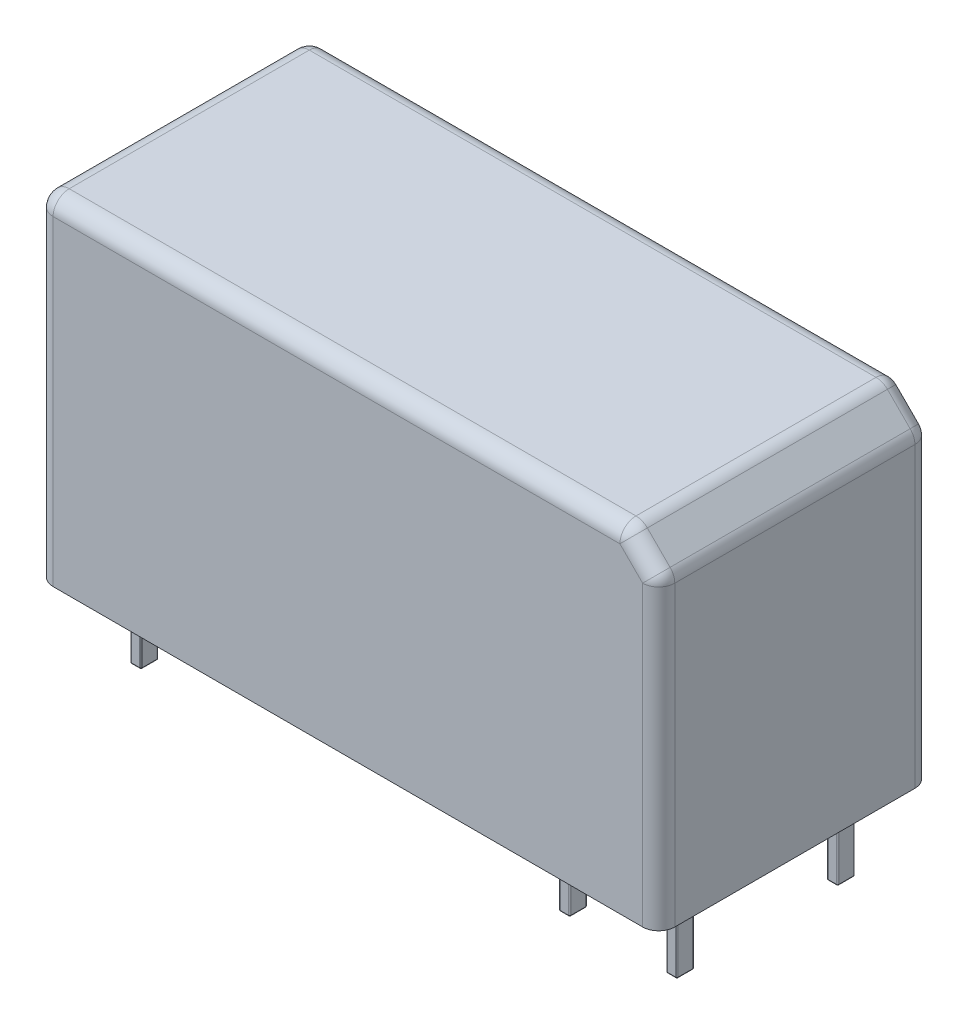
from build123d import *

# Parameters (mm, degrees)
SKETCH_1_W      = 29
SKETCH_1_H      = 12.7
EXTRUDE_1_DEPTH = 15.7
EXTRUDE_2_DEPTH = 3.5
FILLET_1_R      = 0.05
CHAMFER_1_SIZE  = 1.5
FILLET_2_R      = 0.75


with BuildPart() as part:
    # Эскиз1 → Бобышка-Вытянуть1 (new body)
    with BuildSketch(Plane(origin=(0, 0, 0), x_dir=(1, 0, 0), z_dir=(0, 1, 0))):
        Rectangle(SKETCH_1_W, SKETCH_1_H)
    extrude(amount=EXTRUDE_1_DEPTH)

    # Эскиз2 → Бобышка-Вытянуть2 (add)
    with BuildSketch(Plane.XZ):
        with BuildLine():
            Line((-12.3, 4.15), (-11.9, 4.15))
            ThreePointArc((-11.9, 4.15), (-11.864644661, 4.135355339), (-11.85, 4.1))
            Line((-11.85, 4.1), (-11.85, 3.4))
            ThreePointArc((-11.85, 3.4), (-11.864644661, 3.364644661), (-11.9, 3.35))
            Line((-11.9, 3.35), (-12.3, 3.35))
            ThreePointArc((-12.3, 3.35), (-12.335355339, 3.364644661), (-12.35, 3.4))
            Line((-12.35, 3.4), (-12.35, 4.1))
            ThreePointArc((-12.35, 4.1), (-12.335355339, 4.135355339), (-12.3, 4.15))
        make_face()
        with BuildLine():
            Line((7.65, 4.1), (7.65, 3.4))
            ThreePointArc((7.65, 3.4), (7.664644661, 3.364644661), (7.7, 3.35))
            Line((7.7, 3.35), (8.1, 3.35))
            ThreePointArc((8.1, 3.35), (8.135355339, 3.364644661), (8.15, 3.4))
            Line((8.15, 3.4), (8.15, 4.1))
            ThreePointArc((8.15, 4.1), (8.135355339, 4.135355339), (8.1, 4.15))
            Line((8.1, 4.15), (7.7, 4.15))
            ThreePointArc((7.7, 4.15), (7.664644661, 4.135355339), (7.65, 4.1))
        make_face()
        with BuildLine():
            Line((12.65, 4.1), (12.65, 3.4))
            ThreePointArc((12.65, 3.4), (12.664644661, 3.364644661), (12.7, 3.35))
            Line((12.7, 3.35), (13.1, 3.35))
            ThreePointArc((13.1, 3.35), (13.135355339, 3.364644661), (13.15, 3.4))
            Line((13.15, 3.4), (13.15, 4.1))
            ThreePointArc((13.15, 4.1), (13.135355339, 4.135355339), (13.1, 4.15))
            Line((13.1, 4.15), (12.7, 4.15))
            ThreePointArc((12.7, 4.15), (12.664644661, 4.135355339), (12.65, 4.1))
        make_face()
        with BuildLine():
            Line((7.65, -3.4), (7.65, -4.1))
            ThreePointArc((7.65, -4.1), (7.664644661, -4.135355339), (7.7, -4.15))
            Line((7.7, -4.15), (8.1, -4.15))
            ThreePointArc((8.1, -4.15), (8.135355339, -4.135355339), (8.15, -4.1))
            Line((8.15, -4.1), (8.15, -3.4))
            ThreePointArc((8.15, -3.4), (8.135355339, -3.364644661), (8.1, -3.35))
            Line((8.1, -3.35), (7.7, -3.35))
            ThreePointArc((7.7, -3.35), (7.664644661, -3.364644661), (7.65, -3.4))
        make_face()
        with BuildLine():
            Line((12.65, -3.4), (12.65, -4.1))
            ThreePointArc((12.65, -4.1), (12.664644661, -4.135355339), (12.7, -4.15))
            Line((12.7, -4.15), (13.1, -4.15))
            ThreePointArc((13.1, -4.15), (13.135355339, -4.135355339), (13.15, -4.1))
            Line((13.15, -4.1), (13.15, -3.4))
            ThreePointArc((13.15, -3.4), (13.135355339, -3.364644661), (13.1, -3.35))
            Line((13.1, -3.35), (12.7, -3.35))
            ThreePointArc((12.7, -3.35), (12.664644661, -3.364644661), (12.65, -3.4))
        make_face()
        with BuildLine():
            Line((-12.35, -3.4), (-12.35, -4.1))
            ThreePointArc((-12.35, -4.1), (-12.335355339, -4.135355339), (-12.3, -4.15))
            Line((-12.3, -4.15), (-11.9, -4.15))
            ThreePointArc((-11.9, -4.15), (-11.864644661, -4.135355339), (-11.85, -4.1))
            Line((-11.85, -4.1), (-11.85, -3.4))
            ThreePointArc((-11.85, -3.4), (-11.864644661, -3.364644661), (-11.9, -3.35))
            Line((-11.9, -3.35), (-12.3, -3.35))
            ThreePointArc((-12.3, -3.35), (-12.335355339, -3.364644661), (-12.35, -3.4))
        make_face()
    extrude(amount=EXTRUDE_2_DEPTH)

    # Скругление1
    fillet_1_edges = [part.edges().sort_by_distance(p)[0] for p in [
        (12.664644661, -3.5, -4.135355339),
        (12.9, -3.5, -4.15),
        (13.135355339, -3.5, -4.135355339),
        (13.15, -3.5, -3.75),
        (13.135355339, -3.5, -3.364644661),
        (12.9, -3.5, -3.35),
        (12.664644661, -3.5, -3.364644661),
        (12.65, -3.5, -3.75),
        (-12.335355339, -3.5, -4.135355339),
        (-12.1, -3.5, -4.15),
        (-11.864644661, -3.5, -4.135355339),
        (-11.85, -3.5, -3.75),
        (-11.864644661, -3.5, -3.364644661),
        (-12.1, -3.5, -3.35),
        (-12.335355339, -3.5, -3.364644661),
        (-12.35, -3.5, -3.75),
        (-12.335355339, -3.5, 3.364644661),
        (-12.1, -3.5, 3.35),
        (-11.864644661, -3.5, 3.364644661),
        (-11.85, -3.5, 3.75),
        (-11.864644661, -3.5, 4.135355339),
        (-12.1, -3.5, 4.15),
        (-12.335355339, -3.5, 4.135355339),
        (-12.35, -3.5, 3.75),
        (7.664644661, -3.5, 3.364644661),
        (7.9, -3.5, 3.35),
        (8.135355339, -3.5, 3.364644661),
        (8.15, -3.5, 3.75),
        (8.135355339, -3.5, 4.135355339),
        (7.9, -3.5, 4.15),
        (7.664644661, -3.5, 4.135355339),
        (7.65, -3.5, 3.75),
        (12.664644661, -3.5, 3.364644661),
        (12.9, -3.5, 3.35),
        (13.135355339, -3.5, 3.364644661),
        (13.15, -3.5, 3.75),
        (13.135355339, -3.5, 4.135355339),
        (12.9, -3.5, 4.15),
        (12.664644661, -3.5, 4.135355339),
        (12.65, -3.5, 3.75),
        (7.664644661, -3.5, -4.135355339),
        (7.9, -3.5, -4.15),
        (8.135355339, -3.5, -4.135355339),
        (8.15, -3.5, -3.75),
        (8.135355339, -3.5, -3.364644661),
        (7.9, -3.5, -3.35),
        (7.664644661, -3.5, -3.364644661),
        (7.65, -3.5, -3.75),
    ]]
    fillet(fillet_1_edges, radius=FILLET_1_R)

    # Фаска1
    chamfer_1_edges = [part.edges().sort_by_distance(p)[0] for p in [
        (14.5, 15.7, 0),
    ]]
    chamfer(chamfer_1_edges, length=CHAMFER_1_SIZE)

    # Скругление2
    fillet_2_edges = [part.edges().sort_by_distance(p)[0] for p in [
        (-14.5, 15.7, 0),
        (-0.75, 15.7, 6.35),
        (-0.75, 15.7, -6.35),
        (13, 15.7, 0),
        (14.5, 7.1, -6.35),
        (13.75, 14.95, -6.35),
        (14.5, 7.1, 6.35),
        (14.5, 14.2, 0),
        (13.75, 14.95, 6.35),
        (-14.5, 7.85, 6.35),
        (-14.5, 7.85, -6.35),
    ]]
    fillet(fillet_2_edges, radius=FILLET_2_R)


solid = part.part
